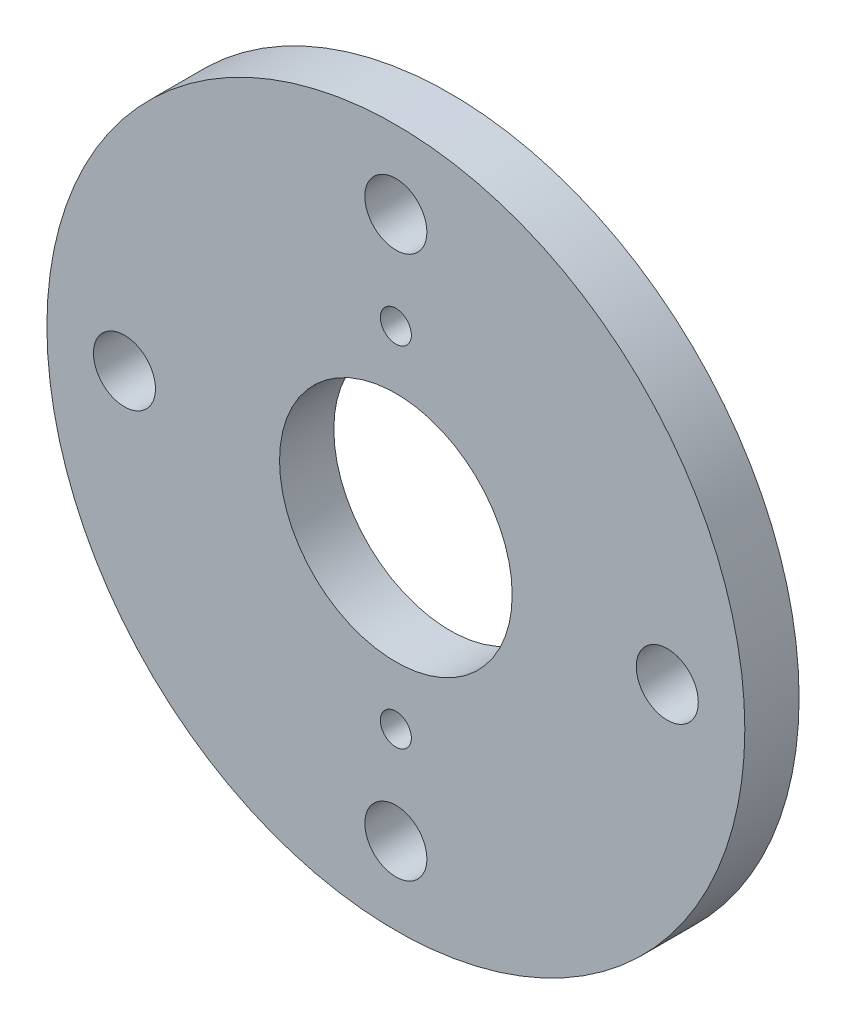
from build123d import *

# Parameters (mm, degrees)
CROQUIS1_R              = 45
SALIENTE_EXTRUIR1_DEPTH = 7
CROQUIS2_R              = 15
CORTAR_EXTRUIR1_DEPTH   = 8
CROQUIS3_R              = 4
CORTAR_EXTRUIR2_DEPTH   = 8
CROQUIS4_R              = 2
CORTAR_EXTRUIR3_DEPTH   = 8


with BuildPart() as part:
    # Croquis1 → Saliente-Extruir1 (new body)
    with BuildSketch(Plane.XY):
        Circle(CROQUIS1_R)
    extrude(amount=SALIENTE_EXTRUIR1_DEPTH)

    # Croquis2 → Cortar-Extruir1 (cut, through all)
    with BuildSketch(Plane.XY.offset(7)):
        Circle(CROQUIS2_R)
    extrude(amount=-CORTAR_EXTRUIR1_DEPTH, mode=Mode.SUBTRACT)

    # Croquis3 → Cortar-Extruir2 (cut, through all)
    with BuildSketch(Plane.XY.offset(7)):
        with Locations((0, 35)):
            Circle(CROQUIS3_R)
        with Locations((35, 0)):
            Circle(CROQUIS3_R)
        with Locations((0, -35)):
            Circle(CROQUIS3_R)
        with Locations((-35, 0)):
            Circle(CROQUIS3_R)
    extrude(amount=-CORTAR_EXTRUIR2_DEPTH, mode=Mode.SUBTRACT)

    # Croquis4 → Cortar-Extruir3 (cut, through all)
    with BuildSketch(Plane.XY.offset(7)):
        with Locations((0, 22.5)):
            Circle(CROQUIS4_R)
        with Locations((0, -22.5)):
            Circle(CROQUIS4_R)
    extrude(amount=-CORTAR_EXTRUIR3_DEPTH, mode=Mode.SUBTRACT)


solid = part.part
